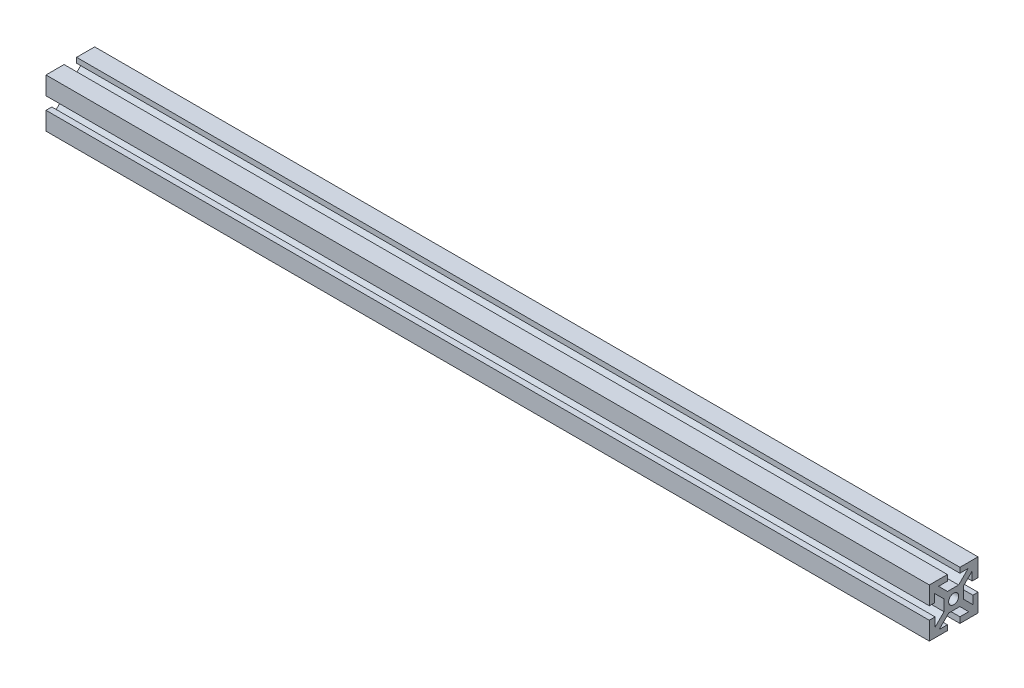
from build123d import *

# Parameters (mm, degrees)
SKETCH1_R           = 2.605
BOSS_EXTRUDE1_DEPTH = 457.2
CIRPATTERN1_COUNT   = 4


with BuildPart() as part:
    # Sketch1 → Boss-Extrude1 (new body)
    with BuildSketch(Plane(origin=(0, 0, 0), x_dir=(0, 0, -1), z_dir=(1, 0, 0))):
        Polygon((5, -5), (5, 3.203948776), (9.596194078, 7.800142853), (9.596194078, 3.24), (12.596194078, 3.24), (12.596194078, 12.596194078), (3.24, 12.596194078), (3.24, 9.921463197), (7.474873734, 9.921463197), (2.553410537, 5), (-5, 5), (-5, -5), align=None)
        Circle(SKETCH1_R, mode=Mode.SUBTRACT)
    boss_extrude1 = extrude(amount=BOSS_EXTRUDE1_DEPTH)

    # CirPattern1: Boss-Extrude1 ×4 about axis
    cirpattern1_axis = Axis((0, 0, 0), (1, 0, 0))
    for i in range(1, CIRPATTERN1_COUNT):
        add(boss_extrude1.rotate(cirpattern1_axis, i * 360 / CIRPATTERN1_COUNT))


solid = part.part
